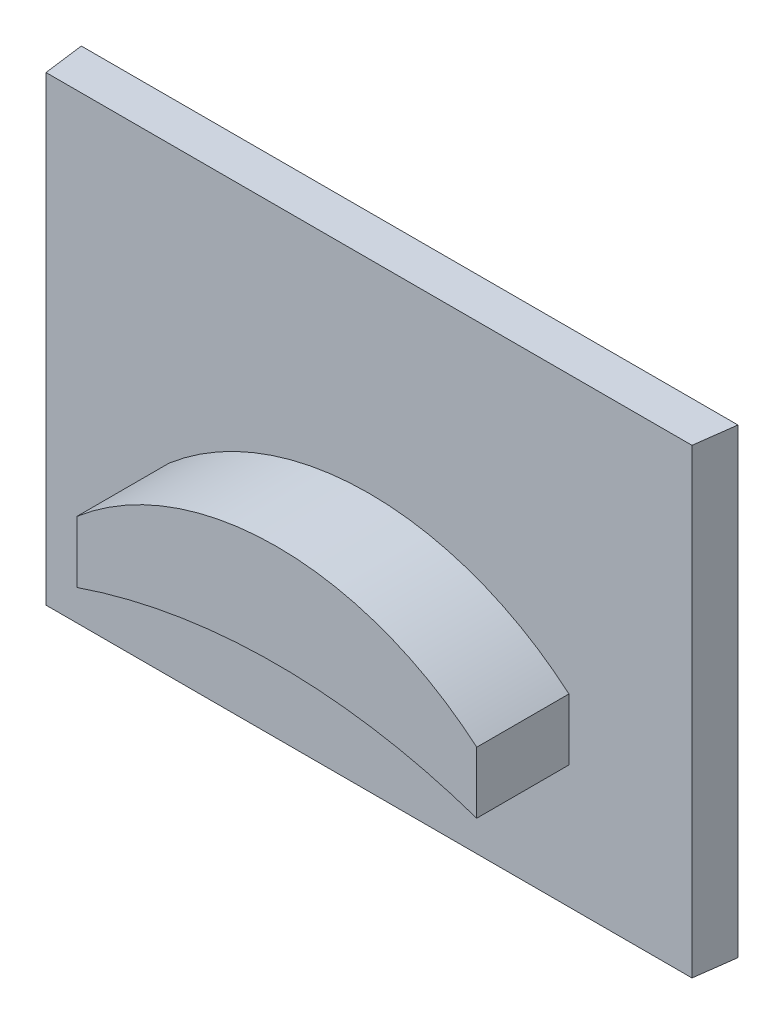
from build123d import *

# Parameters (mm, degrees)
RESSALTO_EXTRUS_O1_DEPTH = 15
RESSALTO_EXTRUS_O2_DEPTH = 3


with BuildPart() as part:
    # Esboço1 → Ressalto-extrusão1 (new body)
    with BuildSketch(Plane(origin=(0, 0, 0), x_dir=(1, 0, 0), z_dir=(0, 1, 0))):
        Polygon((10.484125197, 87.541408798), (10.657910977, 88.861442851), (-10.689651623, 88.857262857), (-10.515874803, 87.537296858), align=None)
    extrude(amount=RESSALTO_EXTRUS_O1_DEPTH)

    # Esboço2 → Ressalto-extrusão2 (add)
    with BuildSketch(Plane(origin=(-0.017140787, 0, -87.53935258), x_dir=(0.999999981, 0, -0.000195807), z_dir=(0.000195807, 0, 0.999999981))):
        with BuildLine():
            Line((-6.498734217, 6), (-6.498734217, 4))
            ThreePointArc((-6.498734217, 4), (0.001265984, 5.08571975), (6.501266185, 4))
            Line((6.501266185, 4), (6.501266185, 6))
            ThreePointArc((6.501266185, 6), (0.001265984, 8.400658095), (-6.498734217, 6))
        make_face()
    extrude(amount=RESSALTO_EXTRUS_O2_DEPTH)


solid = part.part
